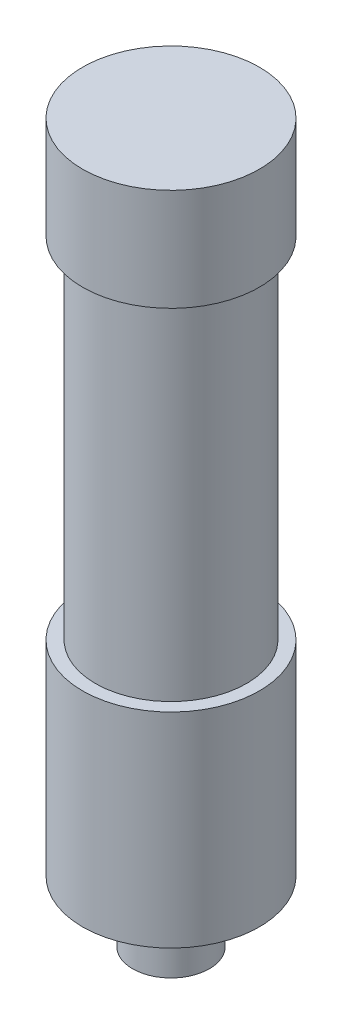
from build123d import *


with BuildPart() as part:
    # Sketch1 → Revolve1 (revolve)
    with BuildSketch(Plane.XY):
        Polygon((0, 25.4), (-10.9855, 25.4), (-10.9855, 12.7), (-9.398, 12.7), (-9.398, -30.734), (-10.9855, -30.734), (-10.9855, -56.134), (-4.7625, -56.134), (-4.7625, -63.754), (0, -63.754), align=None)
    revolve(axis=Axis((0, 25.4, 0), (0, -1, 0)))


solid = part.part
